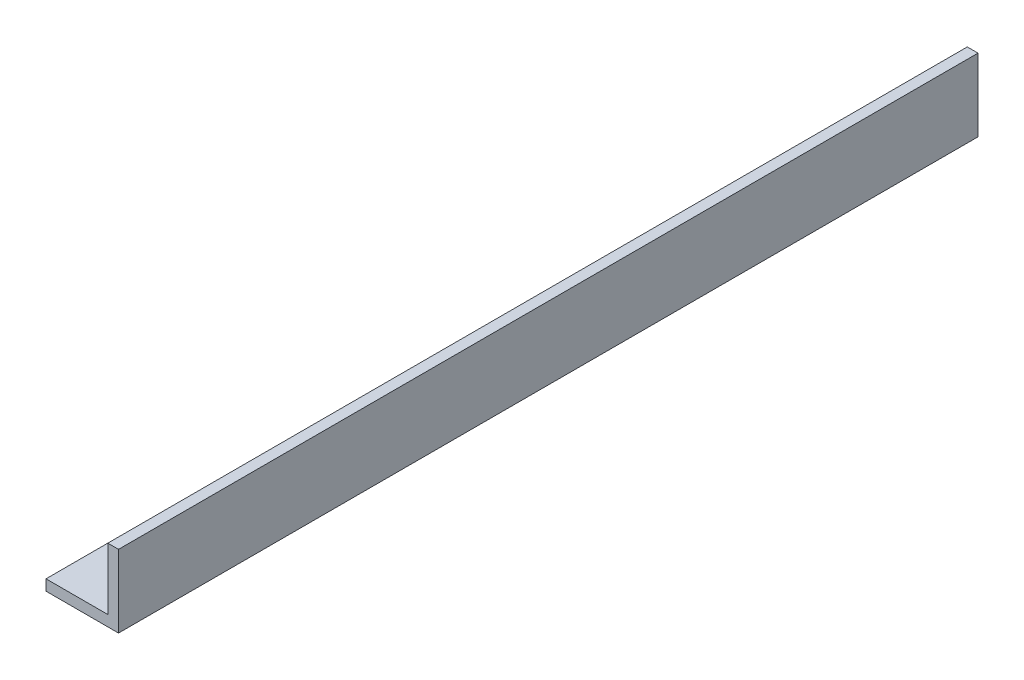
from build123d import *

# Parameters (mm, degrees)
BOSS_EXTRUDE1_DEPTH = 320


with BuildPart() as part:
    # Sketch1 → Boss-Extrude1 (new body)
    with BuildSketch(Plane.XY):
        Polygon((0, 0), (27, 0), (27, 27), (23, 27), (23, 4), (0, 4), align=None)
    extrude(amount=BOSS_EXTRUDE1_DEPTH)


solid = part.part
